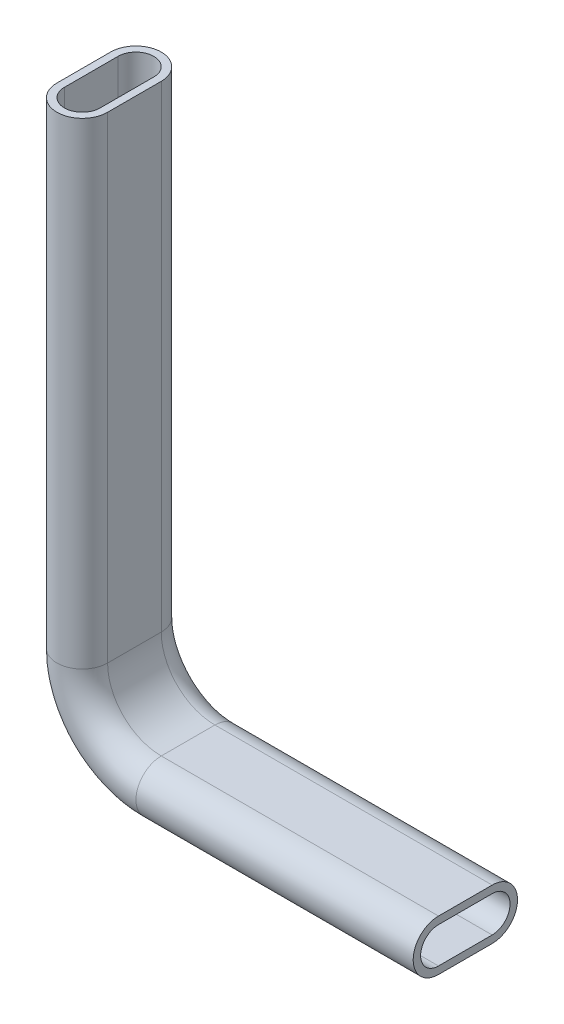
from build123d import *


with BuildPart() as part:
    # Balayage2: sweep along a path in Esquisse2
    with BuildLine(Plane.XY) as balayage2_path:
        Line((-128, 186.5), (-128, 26.5))
        ThreePointArc((-128, 26.5), (-117.748737342, 1.751262658), (-93, -8.5))
        Line((-93, -8.5), (0, -8.5))
    # Esquisse1 → Balayage2 (sweep)
    with BuildSketch(Plane(origin=(0, 0, 0), x_dir=(0, 0, -1), z_dir=(1, 0, 0))):
        with BuildLine():
            Line((-9, -8.5), (9, -8.5))
            ThreePointArc((9, -8.5), (17.5, 0), (9, 8.5))
            Line((9, 8.5), (-9, 8.5))
            ThreePointArc((-9, 8.5), (-17.5, 0), (-9, -8.5))
        make_face()
        with BuildLine():
            Line((-9, 6), (9, 6))
            ThreePointArc((9, 6), (15, 0), (9, -6))
            Line((9, -6), (-9, -6))
            ThreePointArc((-9, -6), (-15, 0), (-9, 6))
        make_face(mode=Mode.SUBTRACT)
    sweep(path=balayage2_path.line)


solid = part.part
